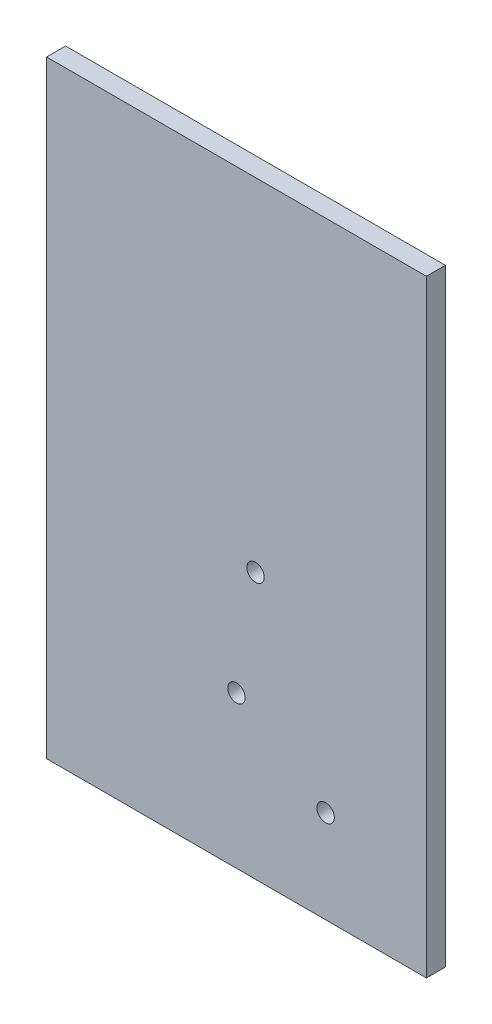
from build123d import *

# Parameters (mm, degrees)
SKETCH1_W           = 127
SKETCH1_H           = 203.2
SKETCH1_R           = 2.921
BOSS_EXTRUDE2_DEPTH = 6.35


with BuildPart() as part:
    # Sketch1 → Boss-Extrude2 (new body)
    with BuildSketch(Plane.XY):
        with Locations((-0.610576923, -62.719413384)):
            Rectangle(SKETCH1_W, SKETCH1_H)
        with Locations((-0.610576923, -113.519413384)):
            Circle(SKETCH1_R, mode=Mode.SUBTRACT)
        with Locations((29.182045889, -133.30869589)):
            Circle(SKETCH1_R, mode=Mode.SUBTRACT)
        with Locations((5.739423077, -75.419413384)):
            Circle(SKETCH1_R, mode=Mode.SUBTRACT)
    extrude(amount=BOSS_EXTRUDE2_DEPTH)


solid = part.part
